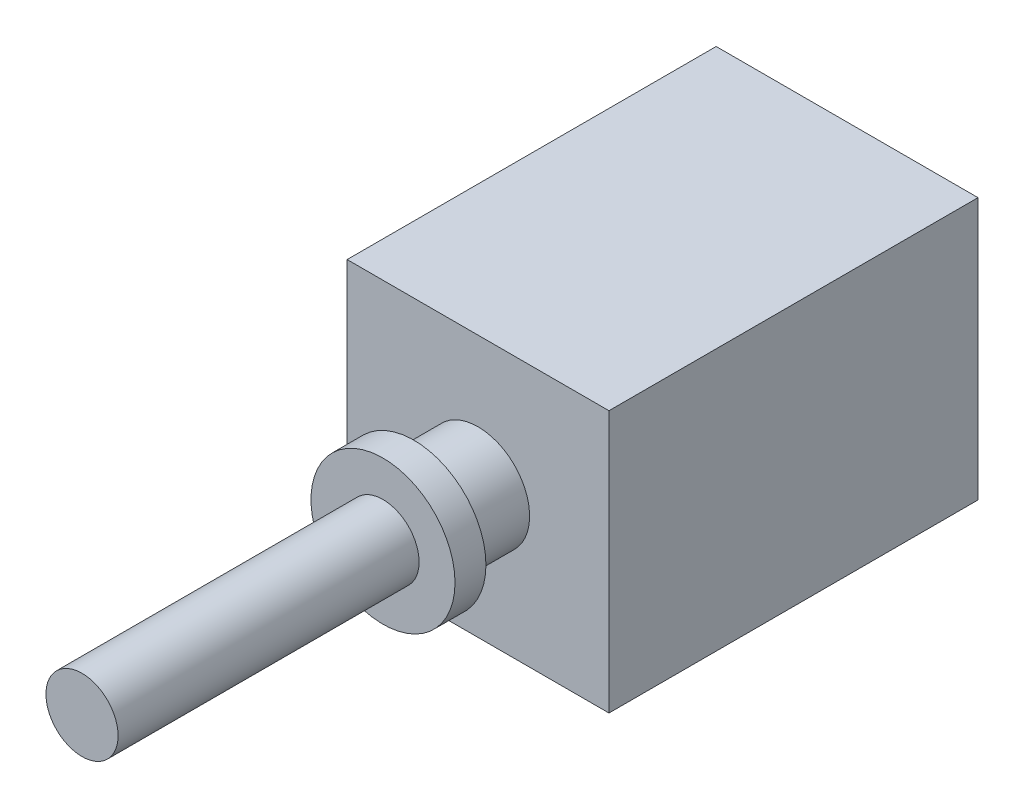
from build123d import *

# Parameters (mm, degrees)
SKETCH1_W           = 127
SKETCH1_H           = 127
BOSS_EXTRUDE1_DEPTH = 179
SKETCH2_R           = 25
BOSS_EXTRUDE2_DEPTH = 31.1
SKETCH3_R           = 34.925
BOSS_EXTRUDE3_DEPTH = 15
SKETCH4_R           = 17.5
BOSS_EXTRUDE4_DEPTH = 146


with BuildPart() as part:
    # Sketch1 → Boss-Extrude1 (new body)
    with BuildSketch(Plane.XY):
        Rectangle(SKETCH1_W, SKETCH1_H)
    extrude(amount=BOSS_EXTRUDE1_DEPTH)

    # Sketch2 → Boss-Extrude2 (add)
    with BuildSketch(Plane.XY.offset(179)):
        Circle(SKETCH2_R)
    extrude(amount=BOSS_EXTRUDE2_DEPTH)

    # Sketch3 → Boss-Extrude3 (add)
    with BuildSketch(Plane.XY.offset(210.1)):
        Circle(SKETCH3_R)
    extrude(amount=BOSS_EXTRUDE3_DEPTH)

    # Sketch4 → Boss-Extrude4 (add)
    with BuildSketch(Plane.XY.offset(225.1)):
        Circle(SKETCH4_R)
    extrude(amount=BOSS_EXTRUDE4_DEPTH)


solid = part.part
